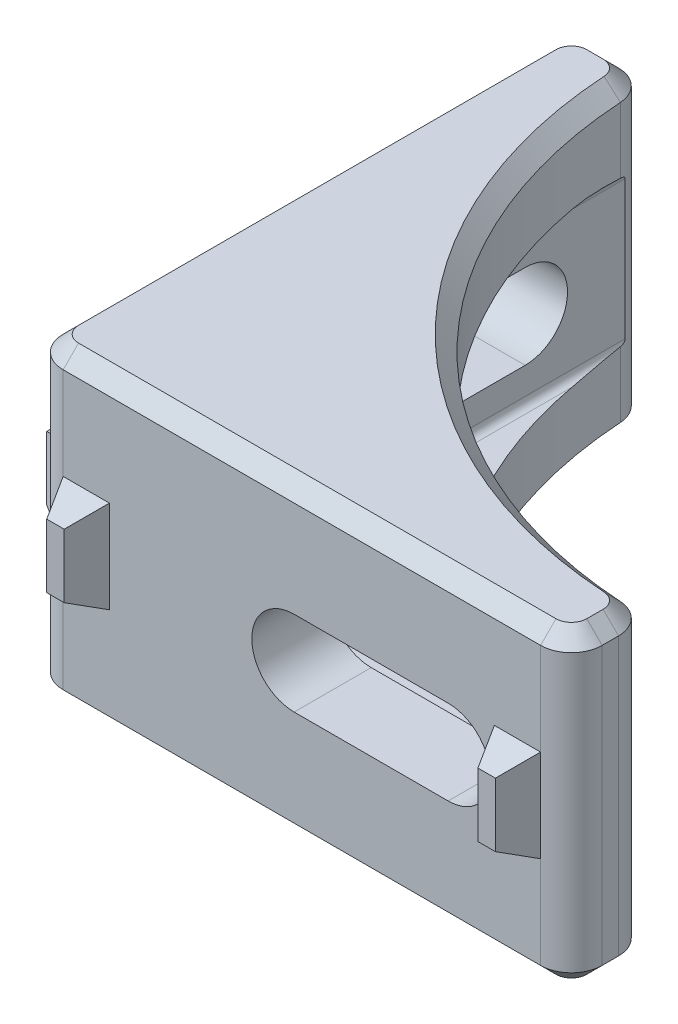
from build123d import *

# Parameters (mm, degrees)
BOSS_EXTRUDE1_DEPTH = 20
CUT_EXTRUDE2_START  = -10
CUT_EXTRUDE2_DEPTH  = 5
CUT_EXTRUDE1_START  = -36
CUT_EXTRUDE1_DEPTH  = 37
SKETCH5_W           = 3
SKETCH5_H           = 6
BOSS_EXTRUDE2_DEPTH = 2
BOSS_EXTRUDE2_TAPER = 25
FILLET1_R           = 8
CHAMFER2_SIZE       = 1
FILLET2_R           = 0.5


with BuildPart() as part:
    # Sketch1 → Boss-Extrude1 (new body)
    with BuildSketch(Plane(origin=(0, 0, 0), x_dir=(1, 0, 0), z_dir=(0, 1, 0))):
        with BuildLine():
            Line((-17.5, 15.5), (-17.5, -15.5))
            ThreePointArc((-17.5, -15.5), (-16.914213562, -16.914213562), (-15.5, -17.5))
            Line((-15.5, -17.5), (15.5, -17.5))
            ThreePointArc((15.5, -17.5), (16.914213562, -16.914213562), (17.5, -15.5))
            Line((17.5, -15.5), (17.5, -14.437438845))
            ThreePointArc((17.5, -14.437438845), (16.957737974, -13.068132452), (15.625, -12.441348918))
            ThreePointArc((15.625, -12.441348918), (-3.713203436, -3.713203436), (-12.441348918, 15.625))
            ThreePointArc((-12.441348918, 15.625), (-13.068132452, 16.957737974), (-14.437438845, 17.5))
            Line((-14.437438845, 17.5), (-15.5, 17.5))
            ThreePointArc((-15.5, 17.5), (-16.914213562, 16.914213562), (-17.5, 15.5))
        make_face()
    extrude(amount=BOSS_EXTRUDE1_DEPTH)

    # Sketch3 → Cut-Extrude2 (cut, symmetric)
    with BuildSketch(Plane(origin=(0, 20, 0), x_dir=(1, 0, 0), z_dir=(0, 1, 0)).offset(CUT_EXTRUDE2_START)):
        Polygon((-12.5, 33.240018262), (-12.5, -12.5), (41.305309001, -12.5), align=None)
    extrude(amount=CUT_EXTRUDE2_DEPTH, both=True, mode=Mode.SUBTRACT)

    # Sketch2 → Cut-Extrude1 (cut)
    with BuildSketch(Plane.ZY.offset(17.5).offset(CUT_EXTRUDE1_START)):
        with BuildLine():
            Line((-9.5, 12.75), (0.5, 12.75))
            ThreePointArc((0.5, 12.75), (3.25, 10), (0.5, 7.25))
            Line((0.5, 7.25), (-9.5, 7.25))
            ThreePointArc((-9.5, 7.25), (-12.25, 10), (-9.5, 12.75))
        make_face()
    cut_extrude1 = extrude(amount=CUT_EXTRUDE1_DEPTH, mode=Mode.SUBTRACT)

    # Sketch5 → Boss-Extrude2 (add)
    with BuildSketch(Plane.ZY.offset(17.5)):
        with Locations((-14, 10)):
            Rectangle(SKETCH5_W, SKETCH5_H)
        with Locations((14, 10)):
            Rectangle(SKETCH5_W, SKETCH5_H)
    boss_extrude2 = extrude(amount=BOSS_EXTRUDE2_DEPTH, taper=BOSS_EXTRUDE2_TAPER)

    # Mirror1: Cut-Extrude1, Boss-Extrude2 across plane
    add(cut_extrude1.mirror(Plane(origin=(0, 0, 0), x_dir=(-0.707106781, 0, 0.707106781), z_dir=(0.707106781, 0, 0.707106781))), mode=Mode.SUBTRACT)
    add(boss_extrude2.mirror(Plane(origin=(0, 0, 0), x_dir=(-0.707106781, 0, 0.707106781), z_dir=(0.707106781, 0, 0.707106781))))

    # Fillet1
    fillet1_edges = [part.edges().sort_by_distance(p)[0] for p in [
        (-12.5, 10, 12.5),
    ]]
    fillet(fillet1_edges, radius=FILLET1_R)

    # Chamfer2
    chamfer2_edges = [part.edges().sort_by_distance(p)[0] for p in [
        (-14.968719423, 0, -17.5),
        (-13.068132452, 0, -16.957737974),
        (-3.713203436, 0, 3.713203436),
        (16.957737974, 0, 13.068132452),
        (17.5, 0, 14.968719423),
        (16.914213562, 0, 16.914213562),
        (0, 0, 17.5),
        (-16.914213562, 20, 16.914213562),
        (-16.914213562, 0, 16.914213562),
        (-17.5, 0, 0),
        (-16.914213562, 0, -16.914213562),
        (0, 20, 17.5),
        (16.914213562, 20, 16.914213562),
        (17.5, 20, 14.968719423),
        (16.957737974, 20, 13.068132452),
        (-3.713203436, 20, 3.713203436),
        (-13.068132452, 20, -16.957737974),
        (-14.968719423, 20, -17.5),
        (-16.914213562, 20, -16.914213562),
        (-17.5, 20, 0),
    ]]
    chamfer(chamfer2_edges, length=CHAMFER2_SIZE)

    # Fillet2
    fillet2_edges = [part.edges().sort_by_distance(p)[0] for p in [
        (5.748158579, 5, 12.5),
        (-10.156854249, 5, 10.156854249),
        (5.748158579, 15, 12.5),
        (-10.156854249, 15, 10.156854249),
        (-12.5, 5, -5.748158579),
        (-12.5, 15, -5.748158579),
    ]]
    fillet(fillet2_edges, radius=FILLET2_R)


solid = part.part
